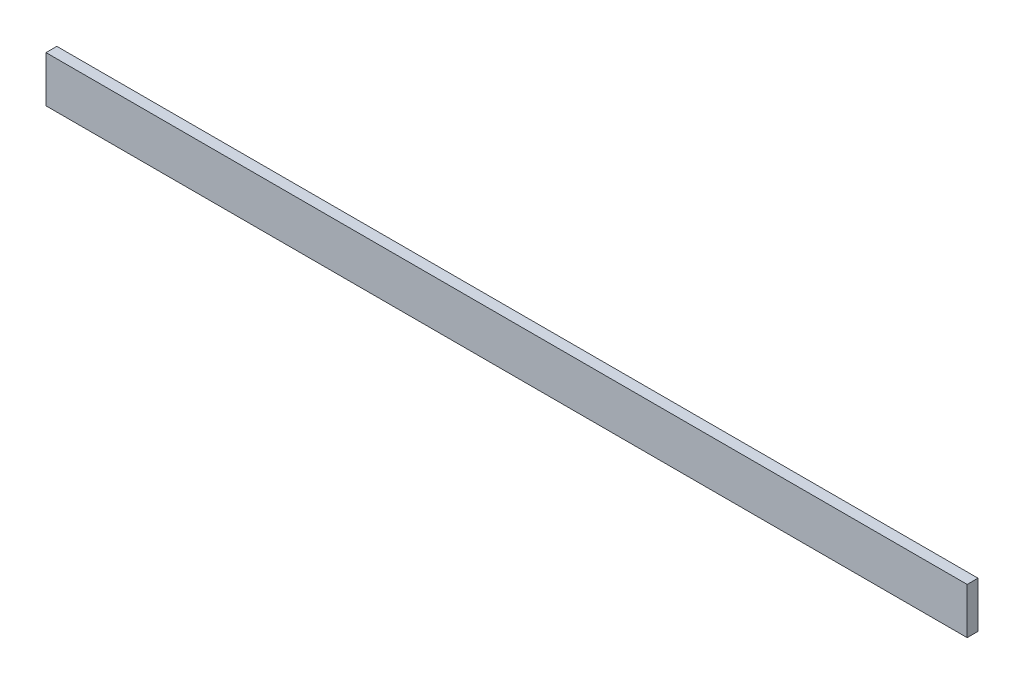
from build123d import *

# Parameters (mm, degrees)
SKETCH1_W           = 1014.476
SKETCH1_H           = 50.8
BOSS_EXTRUDE1_DEPTH = 11.938


with BuildPart() as part:
    # Sketch1 → Boss-Extrude1 (new body)
    with BuildSketch(Plane.XY):
        with Locations((507.238, 25.4)):
            Rectangle(SKETCH1_W, SKETCH1_H)
    extrude(amount=BOSS_EXTRUDE1_DEPTH)


solid = part.part
